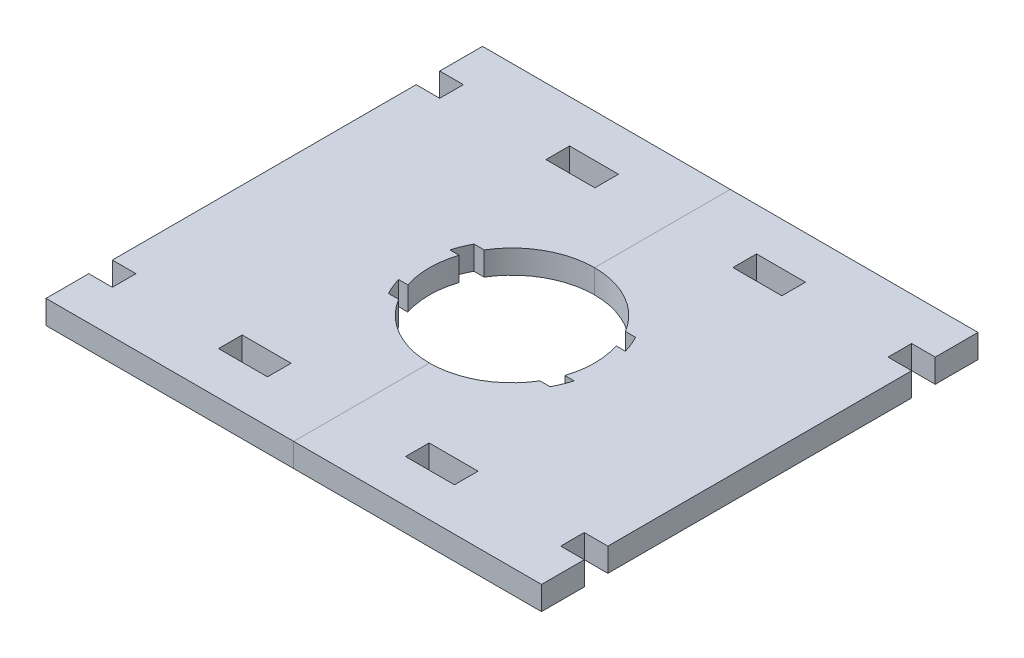
from build123d import *

# Parameters (mm, degrees)
SKETCH2_W               = 84
SKETCH2_H               = 74
BOSS_EXTRUDE1_DEPTH     = 4
SKETCH4_W               = 8.3
SKETCH4_H               = 4
SKETCH4_W_2             = 4
CUT_EXTRUDE2_DEPTH      = 1
CUT_EXTRUDE2_DEPTH_BACK = 5


with BuildPart() as part:
    # Sketch2 → Boss-Extrude1 (new body)
    with BuildSketch(Plane(origin=(0, 0, 0), x_dir=(1, 0, 0), z_dir=(0, 1, 0))):
        Rectangle(SKETCH2_W, SKETCH2_H)
        with BuildLine():
            ThreePointArc((13.307047005, 4.35), (14, 0), (13.307047005, -4.35))
            Line((13.307047005, -4.35), (14.877079687, -4.35))
            ThreePointArc((14.877079687, -4.35), (14.361878956, -5.829788405), (13.699908759, -7.25))
            Line((13.699908759, -7.25), (11.976539567, -7.25))
            ThreePointArc((11.976539567, -7.25), (0, -14), (-11.976539567, -7.25))
            Line((-11.976539567, -7.25), (-13.699908759, -7.25))
            ThreePointArc((-13.699908759, -7.25), (-14.361878956, -5.829788405), (-14.877079687, -4.35))
            Line((-14.877079687, -4.35), (-13.307047005, -4.35))
            ThreePointArc((-13.307047005, -4.35), (-14, 0), (-13.307047005, 4.35))
            Line((-13.307047005, 4.35), (-14.877079687, 4.35))
            ThreePointArc((-14.877079687, 4.35), (-14.361878956, 5.829788405), (-13.699908759, 7.25))
            Line((-13.699908759, 7.25), (-11.976539567, 7.25))
            ThreePointArc((-11.976539567, 7.25), (0, 14), (11.976539567, 7.25))
            Line((11.976539567, 7.25), (13.699908759, 7.25))
            ThreePointArc((13.699908759, 7.25), (14.361878956, 5.829788405), (14.877079687, 4.35))
            Line((14.877079687, 4.35), (13.307047005, 4.35))
        make_face(mode=Mode.SUBTRACT)
    extrude(amount=BOSS_EXTRUDE1_DEPTH)


with BuildPart() as body_2:
    # Split1: the piece on the far side of the plane
    add(part.part)
    split(bisect_by=Plane(origin=(0, 0, 0), x_dir=(0, 0, 1), z_dir=(1, 0, 0)), keep=Keep.BOTTOM)


with BuildPart() as part_1:
    add(part.part)

    # Split1
    split(bisect_by=Plane(origin=(0, 0, 0), x_dir=(0, 0, 1), z_dir=(1, 0, 0)), keep=Keep.TOP)


with BuildPart() as cut_extrude2_tool:
    # Sketch4 → Cut-Extrude2 (new body, two sides)
    with BuildSketch(Plane(origin=(0, 4, 0), x_dir=(1, 0, 0), z_dir=(0, 1, 0))) as cut_extrude2_sk:
        with Locations((-15.85, -27.75)):
            Rectangle(SKETCH4_W, SKETCH4_H)
        with Locations((-40, -27.75)):
            Rectangle(SKETCH4_W_2, SKETCH4_H)
        with Locations((40, -27.75)):
            Rectangle(SKETCH4_W_2, SKETCH4_H)
        with Locations((15.85, -27.75)):
            Rectangle(SKETCH4_W, SKETCH4_H)
        with Locations((15.85, 27.75)):
            Rectangle(SKETCH4_W, SKETCH4_H)
        with Locations((40, 27.75)):
            Rectangle(SKETCH4_W_2, SKETCH4_H)
        with Locations((-40, 27.75)):
            Rectangle(SKETCH4_W_2, SKETCH4_H)
        with Locations((-15.85, 27.75)):
            Rectangle(SKETCH4_W, SKETCH4_H)
    extrude(amount=CUT_EXTRUDE2_DEPTH)
    extrude(cut_extrude2_sk.sketch, amount=-CUT_EXTRUDE2_DEPTH_BACK)


with BuildPart() as part_2:
    add(part_1.part)

    # Cut-Extrude2: cut by cut_extrude2_tool
    add(cut_extrude2_tool.part, mode=Mode.SUBTRACT)


with BuildPart() as body_2_1:
    add(body_2.part)

    # Cut-Extrude2: cut by cut_extrude2_tool
    add(cut_extrude2_tool.part, mode=Mode.SUBTRACT)


solid = Compound([part_2.part, body_2_1.part])
